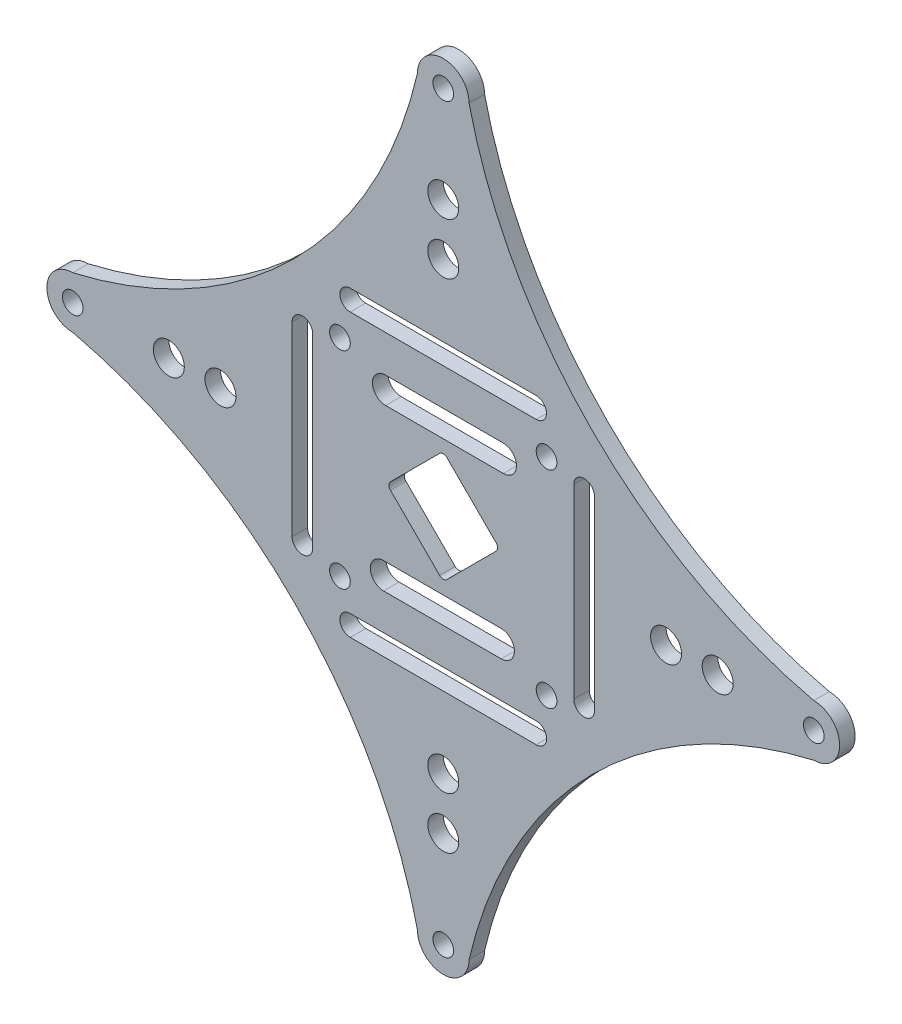
from build123d import *

# Parameters (mm, degrees)
MODEL_R         = 1
MODEL_R_2       = 1.5
EXTRUDE_1_DEPTH = 1.5


with BuildPart() as part:
    # Model → 凸台-拉伸1 (new body)
    with BuildSketch(Plane.XY):
        with BuildLine():
            ThreePointArc((52.402811695, 15.581837899), (64.310189073, 37.053271897), (85.771502284, 48.978880864))
            ThreePointArc((85.771502284, 48.978880864), (88.271502284, 51.478880864), (85.771502284, 53.978880864))
            ThreePointArc((85.771502284, 53.978880864), (64.310189073, 65.90448983), (52.402811695, 87.375923829))
            ThreePointArc((52.402811695, 87.375923829), (49.902811695, 89.875923829), (47.402811695, 87.375923829))
            ThreePointArc((47.402811695, 87.375923829), (35.495434317, 65.90448983), (14.034121106, 53.978880864))
            ThreePointArc((14.034121106, 53.978880864), (11.534121106, 51.478880864), (14.034121106, 48.978880864))
            ThreePointArc((14.034121106, 48.978880864), (35.495434317, 37.053271897), (47.402811695, 15.581837899))
            ThreePointArc((47.402811695, 15.581837899), (49.902811695, 13.081837899), (52.402811695, 15.581837899))
        make_face()
        with Locations((39.902811695, 41.478880864)):
            Circle(MODEL_R, mode=Mode.SUBTRACT)
        with BuildLine():
            Line((37.266458229, 60.471548336), (37.266458229, 42.471548336))
            ThreePointArc((37.266458229, 42.471548336), (36.97356501, 41.764441555), (36.266458229, 41.471548336))
            ThreePointArc((36.266458229, 41.471548336), (35.559351447, 41.764441555), (35.266458229, 42.471548336))
            Line((35.266458229, 42.471548336), (35.266458229, 60.471548336))
            ThreePointArc((35.266458229, 60.471548336), (36.266458229, 61.471548336), (37.266458229, 60.471548336))
        make_face(mode=Mode.SUBTRACT)
        with BuildLine():
            ThreePointArc((55.514109326, 44.893015049), (56.787629095, 43.61949528), (55.514109326, 42.34597551))
            Line((55.514109326, 42.34597551), (44.120323024, 42.345975511))
            ThreePointArc((44.120323024, 42.345975511), (43.219808559, 42.718980816), (42.846803254, 43.619495281))
            ThreePointArc((42.846803254, 43.619495281), (43.219808559, 44.520009746), (44.120323024, 44.89301505))
            Line((44.120323024, 44.89301505), (55.514109326, 44.893015049))
        make_face(mode=Mode.SUBTRACT)
        with Locations((49.902811695, 15.581837899)):
            Circle(MODEL_R, mode=Mode.SUBTRACT)
        with Locations((49.902811695, 24.912124037)):
            Circle(MODEL_R_2, mode=Mode.SUBTRACT)
        with Locations((49.902811695, 29.912124037)):
            Circle(MODEL_R_2, mode=Mode.SUBTRACT)
        with BuildLine():
            Line((58.895479167, 38.842527397), (58.910144223, 38.842527397))
            ThreePointArc((58.910144223, 38.842527397), (59.617251004, 38.549634178), (59.910144223, 37.842527397))
            ThreePointArc((59.910144223, 37.842527397), (59.617251004, 37.135420616), (58.910144223, 36.842527397))
            Line((58.910144223, 36.842527397), (58.895479167, 36.842527397))
            Line((58.895479167, 36.842527397), (40.910144223, 36.842527397))
            Line((40.910144223, 36.842527397), (40.895479167, 36.842527397))
            ThreePointArc((40.895479167, 36.842527397), (40.188372386, 37.135420616), (39.895479167, 37.842527397))
            ThreePointArc((39.895479167, 37.842527397), (40.188372386, 38.549634178), (40.895479167, 38.842527397))
            Line((40.895479167, 38.842527397), (40.910144223, 38.842527397))
            Line((40.910144223, 38.842527397), (58.895479167, 38.842527397))
        make_face(mode=Mode.SUBTRACT)
        with Locations((59.902811695, 41.478880864)):
            Circle(MODEL_R, mode=Mode.SUBTRACT)
        with Locations((14.034121106, 51.478880864)):
            Circle(MODEL_R, mode=Mode.SUBTRACT)
        with Locations((23.336054869, 51.478880864)):
            Circle(MODEL_R_2, mode=Mode.SUBTRACT)
        with Locations((28.336054869, 51.478880864)):
            Circle(MODEL_R_2, mode=Mode.SUBTRACT)
        with Locations((39.902811695, 61.478880864)):
            Circle(MODEL_R, mode=Mode.SUBTRACT)
        with BuildLine():
            Line((58.895479167, 64.11523433), (40.895479167, 64.11523433))
            ThreePointArc((40.895479167, 64.11523433), (40.188372386, 64.408127549), (39.895479167, 65.11523433))
            ThreePointArc((39.895479167, 65.11523433), (40.188372386, 65.822341111), (40.895479167, 66.11523433))
            Line((40.895479167, 66.11523433), (58.895479167, 66.11523433))
            ThreePointArc((58.895479167, 66.11523433), (59.895479167, 65.11523433), (58.895479167, 64.11523433))
        make_face(mode=Mode.SUBTRACT)
        with BuildLine():
            Line((50.256365086, 56.590224257), (55.014155089, 51.832434254))
            ThreePointArc((55.014155089, 51.832434254), (55.160601698, 51.478880864), (55.014155089, 51.125327473))
            Line((55.014155089, 51.125327473), (50.256365086, 46.36753747))
            ThreePointArc((50.256365086, 46.36753747), (49.902811695, 46.221090861), (49.549258305, 46.36753747))
            Line((49.549258305, 46.36753747), (44.791468302, 51.125327473))
            ThreePointArc((44.791468302, 51.125327473), (44.645021692, 51.478880864), (44.791468302, 51.832434254))
            Line((44.791468302, 51.832434254), (49.549258305, 56.590224257))
            ThreePointArc((49.549258305, 56.590224257), (49.902811695, 56.736670867), (50.256365086, 56.590224257))
        make_face(mode=Mode.SUBTRACT)
        with BuildLine():
            Line((44.321526015, 60.538332308), (55.715312317, 60.538332308))
            ThreePointArc((55.715312317, 60.538332308), (56.988832087, 59.264812538), (55.715312317, 57.991292769))
            Line((55.715312317, 57.991292769), (44.321526015, 57.991292769))
            ThreePointArc((44.321526015, 57.991292769), (43.42101155, 58.364298073), (43.048006246, 59.264812538))
            ThreePointArc((43.048006246, 59.264812538), (43.42101155, 60.165327003), (44.321526015, 60.538332308))
        make_face(mode=Mode.SUBTRACT)
        with BuildLine():
            Line((62.539165162, 42.486213392), (62.539165162, 60.486213392))
            ThreePointArc((62.539165162, 60.486213392), (62.832058381, 61.193320173), (63.539165162, 61.486213392))
            ThreePointArc((63.539165162, 61.486213392), (64.246271943, 61.193320173), (64.539165162, 60.486213392))
            Line((64.539165162, 60.486213392), (64.539165162, 42.486213392))
            ThreePointArc((64.539165162, 42.486213392), (63.539165162, 41.486213392), (62.539165162, 42.486213392))
        make_face(mode=Mode.SUBTRACT)
        with Locations((59.902811695, 61.478880864)):
            Circle(MODEL_R, mode=Mode.SUBTRACT)
        with Locations((71.469568521, 51.478880864)):
            Circle(MODEL_R_2, mode=Mode.SUBTRACT)
        with Locations((76.469568521, 51.478880864)):
            Circle(MODEL_R_2, mode=Mode.SUBTRACT)
        with Locations((85.771502284, 51.478880864)):
            Circle(MODEL_R, mode=Mode.SUBTRACT)
        with Locations((49.902811695, 73.04563769)):
            Circle(MODEL_R_2, mode=Mode.SUBTRACT)
        with Locations((49.902811695, 78.04563769)):
            Circle(MODEL_R_2, mode=Mode.SUBTRACT)
        with Locations((49.902811695, 87.375923829)):
            Circle(MODEL_R, mode=Mode.SUBTRACT)
    extrude(amount=EXTRUDE_1_DEPTH)


solid = part.part
